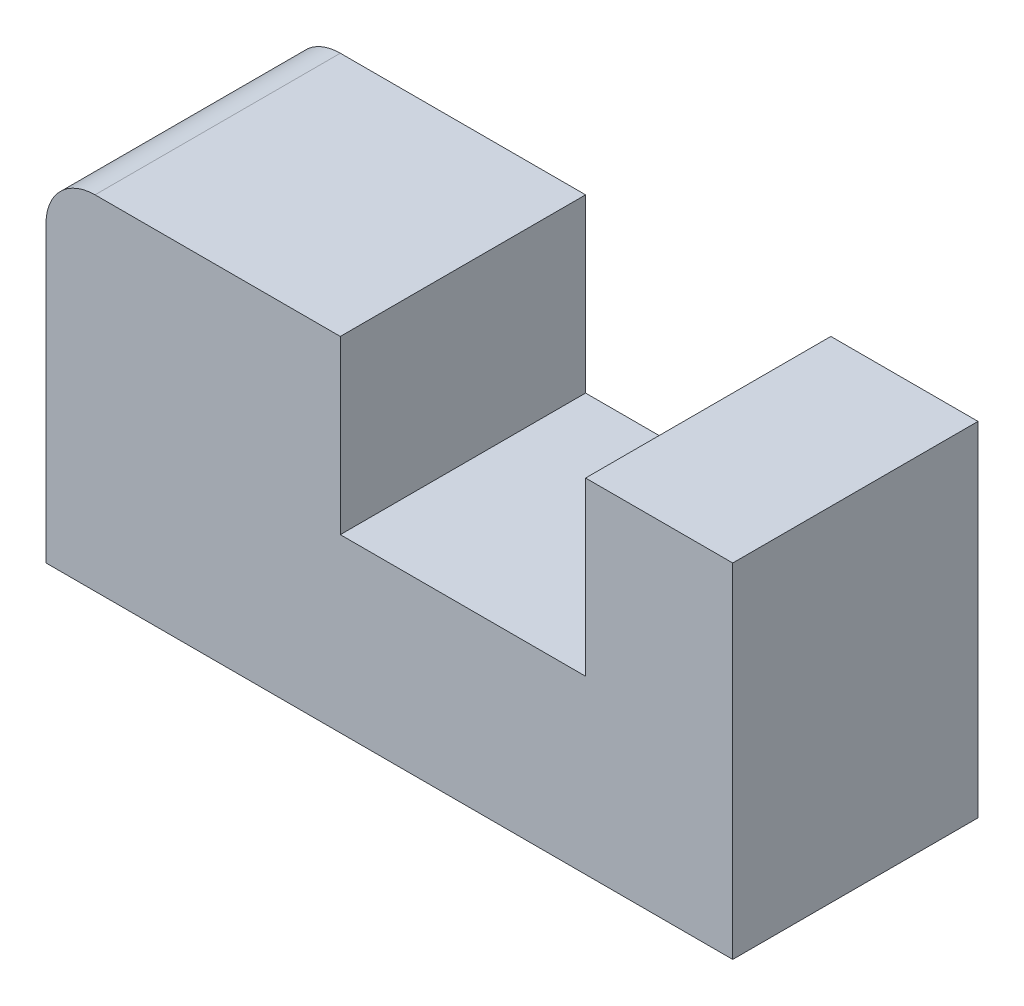
from build123d import *

# Parameters (mm, degrees)
RESSALTO_EXTRUS_O1_DEPTH = 50
FILETE1_R                = 10


with BuildPart() as part:
    # Esboço1 → Ressalto-extrusão1 (new body)
    with BuildSketch(Plane.XY):
        Polygon((-10, 35), (-70, 35), (-70, -35), (70, -35), (70, 35), (40, 35), (40, 0), (-10, 0), align=None)
    extrude(amount=RESSALTO_EXTRUS_O1_DEPTH)

    # Filete1
    filete1_edges = [part.edges().sort_by_distance(p)[0] for p in [
        (-70, 35, 25),
    ]]
    fillet(filete1_edges, radius=FILETE1_R)


solid = part.part
